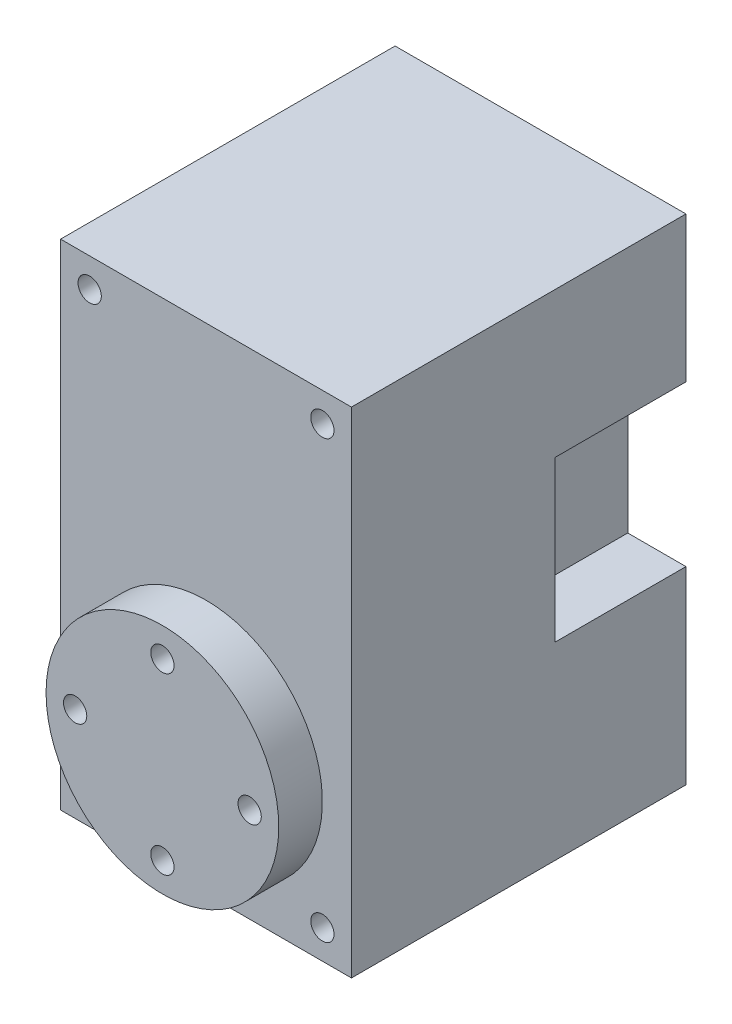
from build123d import *

# Parameters (mm, degrees)
SKETCH1_W           = 20
SKETCH1_H           = 23
BOSS_EXTRUDE1_DEPTH = 34
SKETCH2_R           = 0.8
CUT_EXTRUDE1_DEPTH  = 24
SKETCH3_R           = 8
SKETCH3_R_2         = 0.8
BOSS_EXTRUDE2_DEPTH = 3
SKETCH4_W           = 4
SKETCH4_H           = 11
CUT_EXTRUDE2_DEPTH  = 9


with BuildPart() as part:
    # Sketch1 → Boss-Extrude1 (new body)
    with BuildSketch(Plane(origin=(0, 0, 0), x_dir=(1, 0, 0), z_dir=(0, 1, 0))):
        with Locations((10, 11.5)):
            Rectangle(SKETCH1_W, SKETCH1_H)
    extrude(amount=BOSS_EXTRUDE1_DEPTH)

    # Sketch2 → Cut-Extrude1 (cut, through all)
    with BuildSketch(Plane.XY):
        with Locations((2, 32)):
            Circle(SKETCH2_R)
        with Locations((18, 32)):
            Circle(SKETCH2_R)
        with Locations((18, 2)):
            Circle(SKETCH2_R)
        with Locations((2, 2)):
            Circle(SKETCH2_R)
    extrude(amount=-CUT_EXTRUDE1_DEPTH, mode=Mode.SUBTRACT)

    # Sketch3 → Boss-Extrude2 (add)
    with BuildSketch(Plane.XY):
        with Locations((10, 9.5)):
            Circle(SKETCH3_R)
        with Locations((10, 15.5)):
            Circle(SKETCH3_R_2, mode=Mode.SUBTRACT)
        with Locations((4, 9.5)):
            Circle(SKETCH3_R_2, mode=Mode.SUBTRACT)
        with Locations((10, 3.5)):
            Circle(SKETCH3_R_2, mode=Mode.SUBTRACT)
        with Locations((16, 9.5)):
            Circle(SKETCH3_R_2, mode=Mode.SUBTRACT)
    extrude(amount=BOSS_EXTRUDE2_DEPTH)

    # Sketch4 → Cut-Extrude2 (cut)
    with BuildSketch(Plane(origin=(0, 0, -23), x_dir=(-1, 0, 0), z_dir=(0, 0, -1))):
        with Locations((-18, 18.5)):
            Rectangle(SKETCH4_W, SKETCH4_H)
        with Locations((-2, 18.5)):
            Rectangle(SKETCH4_W, SKETCH4_H)
    extrude(amount=-CUT_EXTRUDE2_DEPTH, mode=Mode.SUBTRACT)


solid = part.part
